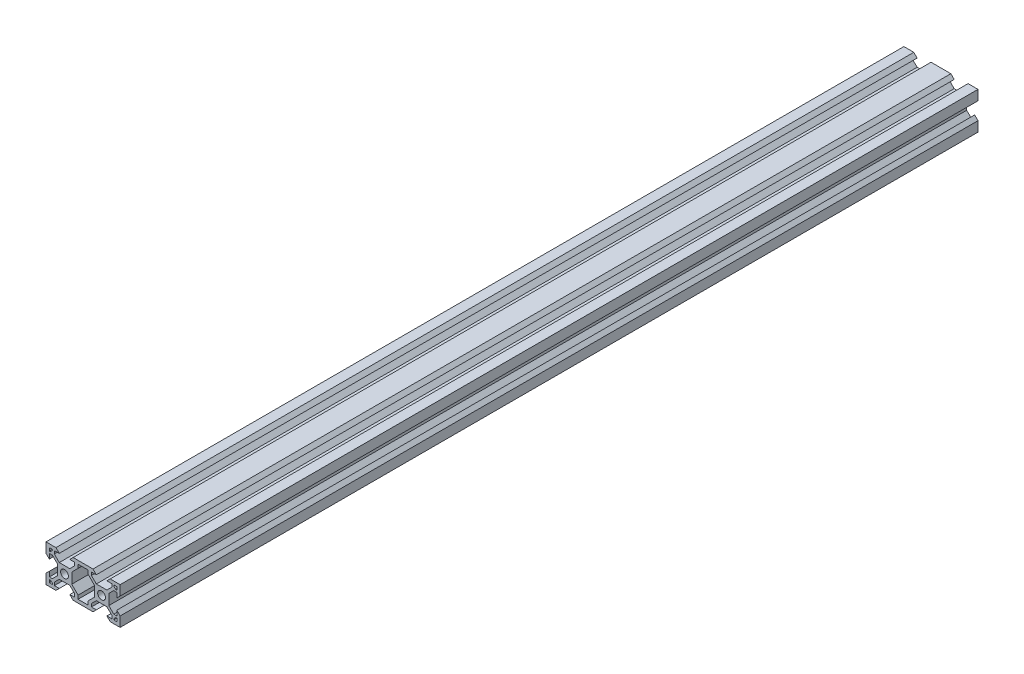
from build123d import *

# Parameters (mm, degrees)
SKETCH1_R           = 2.1
BOSS_EXTRUDE1_DEPTH = 463


with BuildPart() as part:
    # Sketch1 → Boss-Extrude1 (new body)
    with BuildSketch(Plane.XY):
        Polygon((0, 0), (0, 5.36), (1.8, 7.16), (1.8, 4.500660172), (3.44, 4.500660172), (6.099339828, 7.16), (6.099339828, 12.84), (3.44, 15.499339828), (1.8, 15.499339828), (1.8, 12.84), (0, 14.64), (0, 20), (5.36, 20), (7.16, 18.2), (4.500660172, 18.2), (4.500660172, 16.56), (7.16, 13.900660172), (12.84, 13.900660172), (15.499339828, 16.56), (15.499339828, 18.2), (12.84, 18.2), (14.64, 20), (20, 20), (25.36, 20), (27.16, 18.2), (24.500939946, 18.2), (24.50125838, 16.559689577), (27.161114417, 13.900866058), (32.84111431, 13.901968719), (35.499937829, 16.561824756), (35.49961981, 18.2), (32.84, 18.2), (34.64, 20), (39.999930631, 20), (40.000970647, 14.642698508), (38.201320116, 12.842349107), (38.200803857, 15.501688885), (36.560803888, 15.501370511), (33.901980368, 12.841514474), (33.903083029, 7.161514581), (36.562939066, 4.502691062), (38.202939036, 4.503009436), (38.202422777, 7.162349214), (40.002772178, 5.362698683), (40.003813241, 0), (34.64, 0), (32.84, 1.8), (35.502803549, 1.8), (35.502484821, 3.441825004), (32.842628784, 6.100648523), (27.162628891, 6.099545862), (24.503805372, 3.439689825), (24.504123686, 1.8), (27.16, 1.8), (25.36, 0), (20, 0), (14.64, 0), (12.84, 1.8), (15.499339828, 1.8), (15.499339828, 3.44), (12.84, 6.099339828), (7.16, 6.099339828), (4.500660172, 3.44), (4.500660172, 1.8), (7.16, 1.8), (5.36, 0), align=None)
        with Locations((10, 10)):
            Circle(SKETCH1_R, mode=Mode.SUBTRACT)
        with Locations((30, 10)):
            Circle(SKETCH1_R, mode=Mode.SUBTRACT)
        Polygon((17.300660172, 3.76), (17.300660172, 1.8), (22.700660172, 1.8), (22.700660172, 3.76), (26.100660172, 7.16), (26.100660172, 12.84), (22.699339828, 16.24), (22.699339828, 18.2), (17.300660172, 18.2), (17.300660172, 16.24), (13.900660172, 12.84), (13.900660172, 7.16), align=None, mode=Mode.SUBTRACT)
        Polygon((1.8, 18.2), (3.430660172, 18.2), (3.430660172, 17.63), (2.37, 16.569339828), (1.8, 16.569339828), align=None, mode=Mode.SUBTRACT)
        Polygon((1.8, 3.430660172), (1.8, 1.8), (3.430660172, 1.8), (3.430660172, 2.37), (2.37, 3.430660172), align=None, mode=Mode.SUBTRACT)
        Polygon((38.2, 1.8), (36.569339828, 1.8), (36.569339828, 2.37), (37.63, 3.430660172), (38.2, 3.430660172), align=None, mode=Mode.SUBTRACT)
        Polygon((38.2, 16.569339828), (38.2, 18.2), (36.569339828, 18.2), (36.569339828, 17.63), (37.63, 16.569339828), align=None, mode=Mode.SUBTRACT)
    extrude(amount=-BOSS_EXTRUDE1_DEPTH)


solid = part.part
